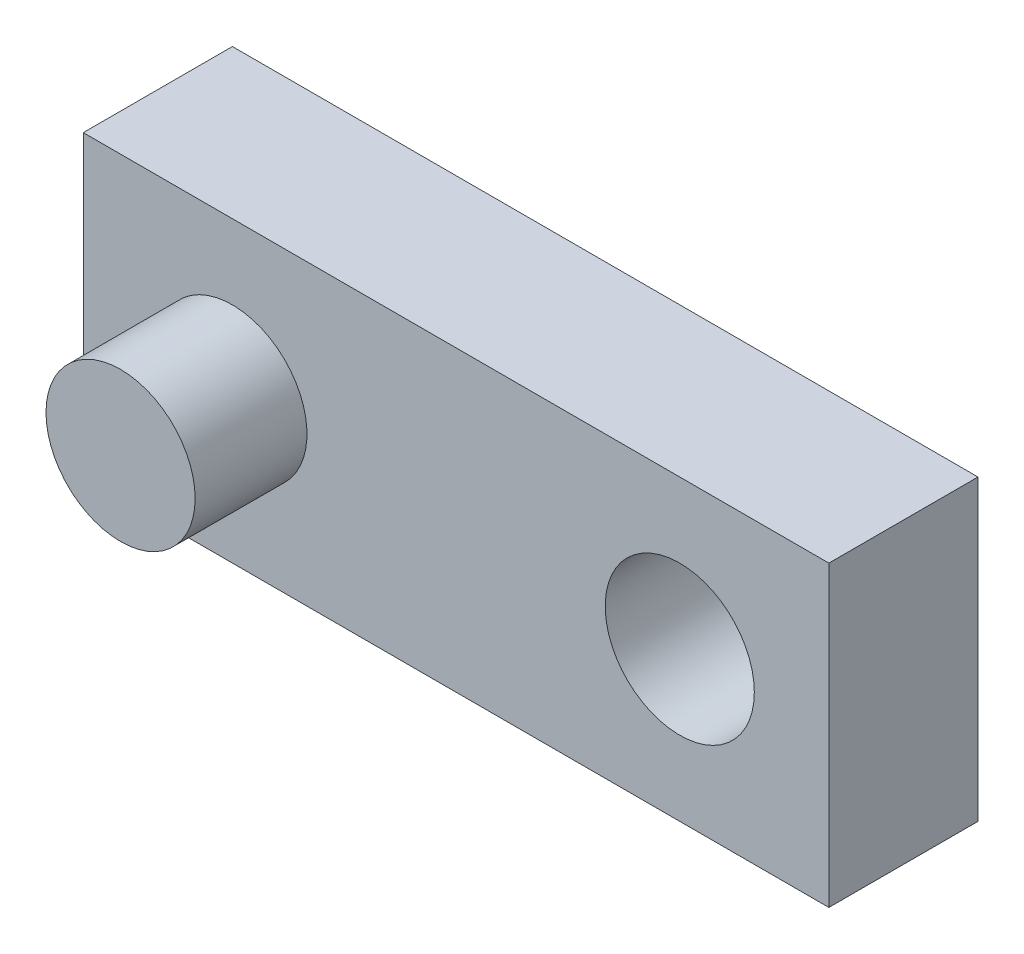
from build123d import *

# Parameters (mm, degrees)
SKETCH1_W           = 2540
SKETCH1_H           = 1016
BOSS_EXTRUDE1_DEPTH = 508
SKETCH2_R           = 254
BOSS_EXTRUDE2_DEPTH = 381
SKETCH3_R           = 254
CUT_EXTRUDE2_DEPTH  = 508


with BuildPart() as part:
    # Sketch1 → Boss-Extrude1 (new body)
    with BuildSketch(Plane.XY):
        Rectangle(SKETCH1_W, SKETCH1_H)
    extrude(amount=BOSS_EXTRUDE1_DEPTH)

    # Sketch2 → Boss-Extrude2 (add)
    with BuildSketch(Plane.XY.offset(508)):
        with Locations((-762, 0)):
            Circle(SKETCH2_R)
    extrude(amount=BOSS_EXTRUDE2_DEPTH)

    # Sketch3 → Cut-Extrude2 (cut)
    with BuildSketch(Plane.XY.offset(508)):
        with Locations((762, 0)):
            Circle(SKETCH3_R)
    extrude(amount=-CUT_EXTRUDE2_DEPTH, mode=Mode.SUBTRACT)


solid = part.part
